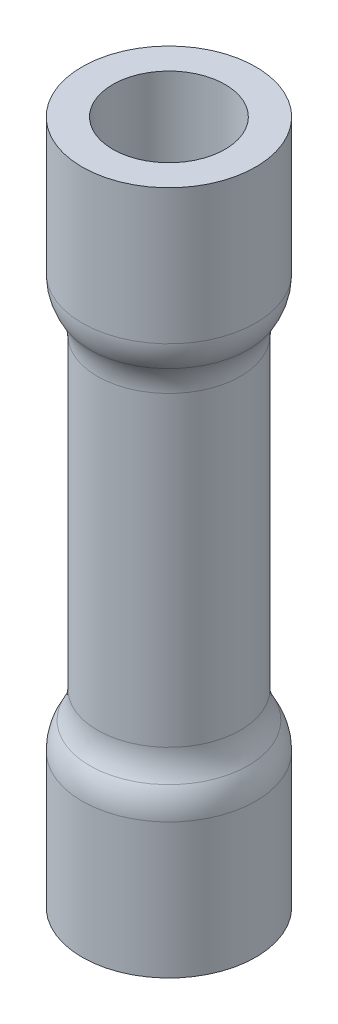
from build123d import *


with BuildPart() as part:
    # Sketch1 → Revolve-Thin1 (revolve)
    with BuildSketch(Plane.XY):
        with BuildLine():
            Line((2.159, 17.018), (2.159, 13.657028027))
            ThreePointArc((2.159, 13.657028027), (2.110446888, 13.309224203), (1.9685, 12.988014013))
            ThreePointArc((1.9685, 12.988014013), (1.826553112, 12.666803824), (1.778, 12.319))
            Line((1.778, 12.319), (1.778, 4.699))
            ThreePointArc((1.778, 4.699), (1.826553112, 4.351196176), (1.9685, 4.029985987))
            ThreePointArc((1.9685, 4.029985987), (2.110446888, 3.708775797), (2.159, 3.360971973))
            Line((2.159, 3.360971973), (2.159, 0))
            Line((2.159, 0), (1.397, 0))
            Line((1.397, 0), (1.397, 3.360971973))
            ThreePointArc((1.397, 3.360971973), (1.377578755, 3.500093503), (1.3208, 3.628577579))
            ThreePointArc((1.3208, 3.628577579), (1.093684979, 4.142513882), (1.016, 4.699))
            Line((1.016, 4.699), (1.016, 12.319))
            ThreePointArc((1.016, 12.319), (1.093684979, 12.875486118), (1.3208, 13.389422421))
            ThreePointArc((1.3208, 13.389422421), (1.377578755, 13.517906497), (1.397, 13.657028027))
            Line((1.397, 13.657028027), (1.397, 17.018))
            Line((1.397, 17.018), (2.159, 17.018))
        make_face()
    revolve(axis=Axis((0, 17.018, 0), (0, -1, 0)))


solid = part.part
